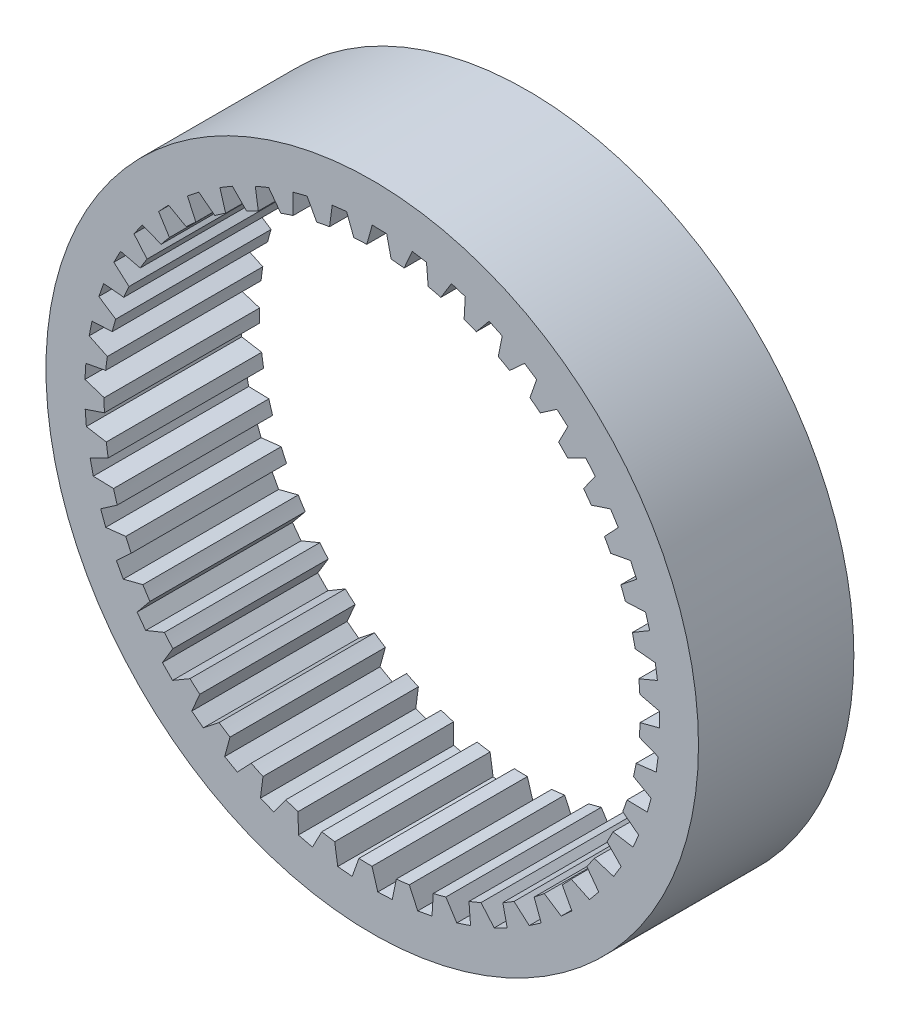
from build123d import *

# Parameters (mm, degrees)
SKETCH1_R           = 21
BOSS_EXTRUDE2_DEPTH = 10


with BuildPart() as part:
    # Sketch1 → Boss-Extrude2 (new body)
    with BuildSketch(Plane.XY):
        Circle(SKETCH1_R)
        with BuildLine():
            Line((-1.188579819, 17.209002819), (-1.648358524, 18.426418919))
            Line((-1.648358524, 18.426418919), (-2.574702368, 18.319959272))
            Line((-2.574702368, 18.319959272), (-2.746319823, 17.029980253))
            ThreePointArc((-2.746319823, 17.029980253), (-3.160118061, 16.958070463), (-3.572042929, 16.876107647))
            Line((-3.572042929, 16.876107647), (-4.196778673, 18.017687109))
            Line((-4.196778673, 18.017687109), (-5.099291083, 17.783341375))
            Line((-5.099291083, 17.783341375), (-5.089707988, 16.48203181))
            ThreePointArc((-5.089707988, 16.48203181), (-5.489471262, 16.353232257), (-5.885980286, 16.214738236))
            Line((-5.885980286, 16.214738236), (-6.663513299, 17.258261515))
            Line((-6.663513299, 17.258261515), (-7.524627897, 16.900590966))
            Line((-7.524627897, 16.900590966), (-7.334030777, 15.613279366))
            ThreePointArc((-7.334030777, 15.613279366), (-7.711978149, 15.430096987), (-8.085353732, 15.23776739))
            Line((-8.085353732, 15.23776739), (-9.000550217, 16.162923491))
            Line((-9.000550217, 16.162923491), (-9.803506388, 15.688889779))
            Line((-9.803506388, 15.688889779), (-9.435604999, 14.440632199))
            ThreePointArc((-9.435604999, 14.440632199), (-9.784380154, 14.20663243), (-10.127354965, 13.964210734))
            Line((-10.127354965, 13.964210734), (-11.162401664, 14.752992547))
            Line((-11.162401664, 14.752992547), (-11.891570779, 14.171822198))
            Line((-11.891570779, 14.171822198), (-11.353525903, 12.986914552))
            ThreePointArc((-11.353525903, 12.986914552), (-11.666340328, 12.706651933), (-11.972238753, 12.4188566))
            Line((-11.972238753, 12.4188566), (-13.10698966, 13.055911384))
            Line((-13.10698966, 13.055911384), (-13.748179271, 12.378916218))
            Line((-13.748179271, 12.378916218), (-13.050463339, 11.280421385))
            ThreePointArc((-13.050463339, 11.280421385), (-13.321228458, 10.95935091), (-13.584096532, 10.631783548))
            Line((-13.584096532, 10.631783548), (-14.796465011, 11.104711756))
            Line((-14.796465011, 11.104711756), (-15.337195092, 10.345068714))
            Line((-15.337195092, 10.345068714), (-14.493388352, 9.354367648))
            ThreePointArc((-14.493388352, 9.354367648), (-14.716834029, 8.998738587), (-14.931555323, 8.637774924))
            Line((-14.931555323, 8.637774924), (-16.197944001, 8.937371546))
            Line((-16.197944001, 8.937371546), (-16.627689857, 8.109866216))
            Line((-16.627689857, 8.109866216), (-15.654216045, 7.246241785))
            ThreePointArc((-15.654216045, 7.246241785), (-15.825993166, 6.862976053), (-15.988388375, 6.475641835))
            Line((-15.988388375, 6.475641835), (-17.284148436, 6.596075565))
            Line((-17.284148436, 6.596075565), (-17.594545551, 5.716814396))
            Line((-17.594545551, 5.716814396), (-16.510352231, 4.997076068))
            ThreePointArc((-16.510352231, 4.997076068), (-16.627117348, 4.593633497), (-16.734025633, 4.187467745))
            Line((-16.734025633, 4.187467745), (-18.033936582, 4.126394476))
            Line((-18.033936582, 4.126394476), (-18.218943431, 3.212491287))
            Line((-18.218943431, 3.212491287), (-17.04513319, 2.650647949))
            ThreePointArc((-17.04513319, 2.650647949), (-17.104613603, 2.234881091), (-17.153954117, 1.817789358))
            Line((-17.153954117, 1.817789358), (-18.432714665, 1.576397812))
            Line((-18.432714665, 1.576397812), (-18.4887303, 0.645640689))
            Line((-18.4887303, 0.645640689), (-17.24815002, 0.252627983))
            ThreePointArc((-17.24815002, 0.252627983), (-17.249188011, -0.167370734), (-17.240000397, -0.587270232))
            Line((-17.240000397, -0.587270232), (-18.472720925, -1.004281642))
            Line((-18.472720925, -1.004281642), (-18.398655064, -1.93377657))
            Line((-18.398655064, -1.93377657), (-17.115451229, -2.150309099))
            ThreePointArc((-17.115451229, -2.150309099), (-17.058026595, -2.566364878), (-16.990489679, -2.980899274))
            Line((-16.990489679, -2.980899274), (-18.153176685, -3.565413897))
            Line((-18.153176685, -3.565413897), (-17.950470936, -4.475555069))
            Line((-17.950470936, -4.475555069), (-16.649619649, -4.511392861))
            ThreePointArc((-16.649619649, -4.511392861), (-16.534850094, -4.915407649), (-16.410278405, -5.316508502))
            Line((-16.410278405, -5.316508502), (-17.480301509, -6.057149425))
            Line((-17.480301509, -6.057149425), (-17.152901309, -6.930221978))
            Line((-17.152901309, -6.930221978), (-15.859722161, -6.784667492))
            ThreePointArc((-15.859722161, -6.784667492), (-15.689841545, -7.168777601), (-15.51065973, -7.54863794))
            Line((-15.51065973, -7.54863794), (-16.467192148, -8.43098943))
            Line((-16.467192148, -8.43098943), (-16.02146997, -9.25))
            Line((-16.02146997, -9.25), (-14.761133221, -8.925886288))
            ThreePointArc((-14.761133221, -8.925886288), (-14.539448077, -9.282615452), (-14.309143705, -9.633841727))
            Line((-14.309143705, -9.633841727), (-15.133567622, -10.640729816))
            Line((-15.133567622, -10.640729816), (-14.578198942, -11.389737294))
            Line((-14.578198942, -11.389737294), (-13.375235614, -10.89337286))
            ThreePointArc((-13.375235614, -10.89337286), (-13.10606079, -11.215777752), (-12.829116475, -11.531533743))
            Line((-12.829116475, -11.531533743), (-13.505385418, -12.6433605))
            Line((-13.505385418, -12.6433605), (-12.851179853, -13.307786306))
            Line((-12.851179853, -13.307786306), (-11.72900426, -12.648832321))
            ThreePointArc((-11.72900426, -12.648832321), (-11.417578938, -12.930637695), (-11.099385085, -13.204777572))
            Line((-11.099385085, -13.204777572), (-11.614336248, -14.399902552))
            Line((-11.614336248, -14.399902552), (-10.874027167, -14.966814396))
            Line((-10.874027167, -14.966814396), (-9.854481179, -14.158096648))
            ThreePointArc((-9.854481179, -14.158096648), (-9.506866899, -14.393817484), (-9.15361679, -14.621005426))
            Line((-9.15361679, -14.621005426), (-9.497227234, -15.876166882))
            Line((-9.497227234, -15.876166882), (-8.685223912, -16.334530468))
            Line((-8.685223912, -16.334530468), (-7.788151831, -15.391789729))
            ThreePointArc((-7.788151831, -15.391789729), (-7.41111451, -15.576837989), (-7.029683757, -15.75265204))
            Line((-7.029683757, -15.75265204), (-7.195265495, -17.043419682))
            Line((-7.195265495, -17.043419682), (-6.327372652, -17.384313485))
            Line((-6.327372652, -17.384313485), (-5.570234967, -16.32589913))
            ThreePointArc((-5.570234967, -16.32589913), (-5.171113207, -16.45667306), (-4.768925925, -16.5776912))
            Line((-4.768925925, -16.5776912), (-4.753256098, -17.878941704))
            Line((-4.753256098, -17.878941704), (-3.84636628, -18.095730614))
            Line((-3.84636628, -18.095730614), (-3.243899815, -16.942243476))
            ThreePointArc((-3.243899815, -16.942243476), (-2.830462067, -17.016197709), (-2.415346375, -17.080064458))
            Line((-2.415346375, -17.080064458), (-2.218729977, -18.366470464))
            Line((-2.218729977, -18.366470464), (-1.290494764, -18.45493493))
            Line((-1.290494764, -18.45493493), (-0.854425844, -17.228826323))
            ThreePointArc((-0.854425844, -17.228826323), (-0.434719203, -17.244521426), (-0.014754855, -17.24999369))
            Line((-0.014754855, -17.24999369), (0.358981198, -18.496516767))
            Line((0.358981198, -18.496516767), (1.290494764, -18.45493493))
            Line((1.290494764, -18.45493493), (1.551678555, -17.180069664))
            ThreePointArc((1.551678555, -17.180069664), (1.969484975, -17.137200149), (2.386123852, -17.084171416))
            Line((2.386123852, -17.084171416), (2.929705213, -18.26654941))
            Line((2.929705213, -18.26654941), (3.84636628, -18.095730614))
            Line((3.84636628, -18.095730614), (3.927581296, -16.796922491))
            ThreePointArc((3.927581296, -16.796922491), (4.335355369, -16.696322763), (4.740559372, -16.585825178))
            Line((4.740559372, -16.585825178), (5.443405849, -17.681044448))
            Line((5.443405849, -17.681044448), (6.327372652, -17.384313485))
            Line((6.327372652, -17.384313485), (6.227038135, -16.086842328))
            ThreePointArc((6.227038135, -16.086842328), (6.616843003, -15.930470448), (7.002725296, -15.76465472))
            Line((7.002725296, -15.76465472), (7.851156781, -16.751398067))
            Line((7.851156781, -16.751398067), (8.685223912, -16.334530468))
            Line((8.685223912, -16.334530468), (8.405292759, -15.063650077))
            ThreePointArc((8.405292759, -15.063650077), (8.769541313, -14.854549645), (9.128591138, -14.636643189))
            Line((9.128591138, -14.636643189), (10.106093878, -15.495704777))
            Line((10.106093878, -15.495704777), (10.874027167, -14.966814396))
            Line((10.874027167, -14.966814396), (10.419947921, -13.747261012))
            ThreePointArc((10.419947921, -13.747261012), (10.751550478, -13.48950193), (11.076779337, -13.223746048))
            Line((11.076779337, -13.223746048), (12.164327352, -13.93840522))
            Line((12.164327352, -13.93840522), (12.851179853, -13.307786306))
            Line((12.851179853, -13.307786306), (12.231790648, -12.163297149))
            ThreePointArc((12.231790648, -12.163297149), (12.524292941, -11.861896405), (12.809370625, -11.553463731))
            Line((12.809370625, -11.553463731), (13.985796031, -12.10981046))
            Line((13.985796031, -12.10981046), (14.578198942, -11.389737294))
            Line((14.578198942, -11.389737294), (13.805555485, -10.342588542))
            ThreePointArc((13.805555485, -10.342588542), (14.053264289, -10.003412558), (14.292642085, -9.658306385))
            Line((14.292642085, -9.658306385), (15.535047099, -10.045512014))
            Line((15.535047099, -10.045512014), (16.02146997, -9.25))
            Line((16.02146997, -9.25), (15.110610887, -8.320573214))
            ThreePointArc((15.110610887, -8.320573214), (15.308704833, -7.950223665), (15.497723524, -7.575161091))
            Line((15.497723524, -7.575161091), (16.781926147, -7.785689103))
            Line((16.781926147, -7.785689103), (17.152901309, -6.930221978))
            Line((17.152901309, -6.930221978), (16.121555437, -6.136607393))
            ThreePointArc((16.121555437, -6.136607393), (16.266178851, -5.742292712), (16.401159404, -5.344573904))
            Line((16.401159404, -5.344573904), (17.702164091, -5.37432661))
            Line((17.702164091, -5.37432661), (17.950470936, -4.475555069))
            Line((17.950470936, -4.475555069), (16.818712248, -3.833199489))
            ThreePointArc((16.818712248, -3.833199489), (16.9070502, -3.422594562), (16.985365371, -3.009960664))
            Line((16.985365371, -3.009960664), (18.277849546, -2.858358963))
            Line((18.277849546, -2.858358963), (18.398655064, -1.93377657))
            Line((18.398655064, -1.93377657), (17.188511956, -1.455182718))
            ThreePointArc((17.188511956, -1.455182718), (17.218845048, -1.036279503), (17.238970523, -0.616761964))
            Line((17.238970523, -0.616761964), (18.497777452, -0.286756609))
            Line((18.497777452, -0.286756609), (18.4887303, 0.645640689))
            Line((18.4887303, 0.645640689), (17.22375683, 0.95115753))
            ThreePointArc((17.22375683, 0.95115753), (17.195494664, 1.370205558), (17.157038722, 1.788441306))
            Line((17.157038722, 1.788441306), (18.357667159, 2.290427135))
            Line((18.357667159, 2.290427135), (18.218943431, 3.212491287))
            Line((18.218943431, 3.212491287), (16.92376087, 3.338984579))
            ThreePointArc((16.92376087, 3.338984579), (16.837453535, 3.750021127), (16.741164678, 4.1588346))
            Line((16.741164678, 4.1588346), (17.860245758, 4.823030321))
            Line((17.860245758, 4.823030321), (17.594545551, 5.716814396))
            Line((17.594545551, 5.716814396), (16.294363155, 5.66182209))
            ThreePointArc((16.294363155, 5.66182209), (16.151690526, 6.0568468), (15.999442906, 6.44828091))
            Line((15.999442906, 6.44828091), (17.015194988, 7.261758707))
            Line((17.015194988, 7.261758707), (16.627689857, 8.109866216))
            Line((16.627689857, 8.109866216), (15.347814195, 7.874458675))
            ThreePointArc((15.347814195, 7.874458675), (15.151553233, 8.245782839), (14.946310178, 8.612218766))
            Line((14.946310178, 8.612218766), (15.838962802, 9.55914522))
            Line((15.838962802, 9.55914522), (15.337195092, 10.345068714))
            Line((15.337195092, 10.345068714), (14.10253749, 9.933827879))
            ThreePointArc((14.10253749, 9.933827879), (13.856508191, 10.274224095), (13.602264523, 10.60852958))
            Line((13.602264523, 10.60852958), (14.354443222, 11.670473845))
            Line((14.354443222, 11.670473845), (13.748179271, 12.378916218))
            Line((13.748179271, 12.378916218), (12.582770934, 11.799846423))
            ThreePointArc((12.582770934, 11.799846423), (12.291761978, 12.102689266), (11.993466261, 12.398357433))
            Line((11.993466261, 12.398357433), (12.590530733, 13.554649972))
            Line((12.590530733, 13.554649972), (11.891570779, 14.171822198))
            Line((11.891570779, 14.171822198), (10.818095055, 13.436194379))
            ThreePointArc((10.818095055, 13.436194379), (10.4877706, 13.695589357), (10.151228821, 13.946865362))
            Line((10.151228821, 13.946865362), (10.581557884, 15.175000255))
            Line((10.581557884, 15.175000255), (9.803506388, 15.688889779))
            Line((9.803506388, 15.688889779), (8.842857261, 14.811022094))
            ThreePointArc((8.842857261, 14.811022094), (8.479646698, 15.021920379), (8.111409259, 15.223913421))
            Line((8.111409259, 15.223913421), (8.366627048, 16.49998642))
            Line((8.366627048, 16.49998642), (7.524627897, 16.900590966))
            Line((7.524627897, 16.900590966), (6.695503309, 15.897570111))
            ThreePointArc((6.695503309, 15.897570111), (6.306476117, 16.055866809), (5.913710342, 16.204645321))
            Line((5.913710342, 16.204645321), (5.988849333, 17.503819117))
            Line((5.988849333, 17.503819117), (5.099291083, 17.783341375))
            Line((5.099291083, 17.783341375), (4.417829001, 16.67469001))
            ThreePointArc((4.417829001, 16.67469001), (4.010557153, 16.777304054), (3.60090778, 16.869972233))
            Line((3.60090778, 16.869972233), (3.494505477, 18.166959885))
            Line((3.494505477, 18.166959885), (2.574702368, 18.319959272))
            Line((2.574702368, 18.319959272), (2.054166676, 17.127256034))
            ThreePointArc((2.054166676, 17.127256034), (1.636577255, 17.17219016), (1.218017644, 17.206944325))
            Line((1.218017644, 17.206944325), (0.932145048, 18.476501444))
            Line((0.932145048, 18.476501444), (0, 18.5))
            Line((0, 18.5), (-0.349477666, 17.246459502))
            ThreePointArc((-0.349477666, 17.246459502), (-0.769256757, 17.232839117), (-1.188579819, 17.209002819))
        make_face(mode=Mode.SUBTRACT)
    extrude(amount=BOSS_EXTRUDE2_DEPTH)


solid = part.part
